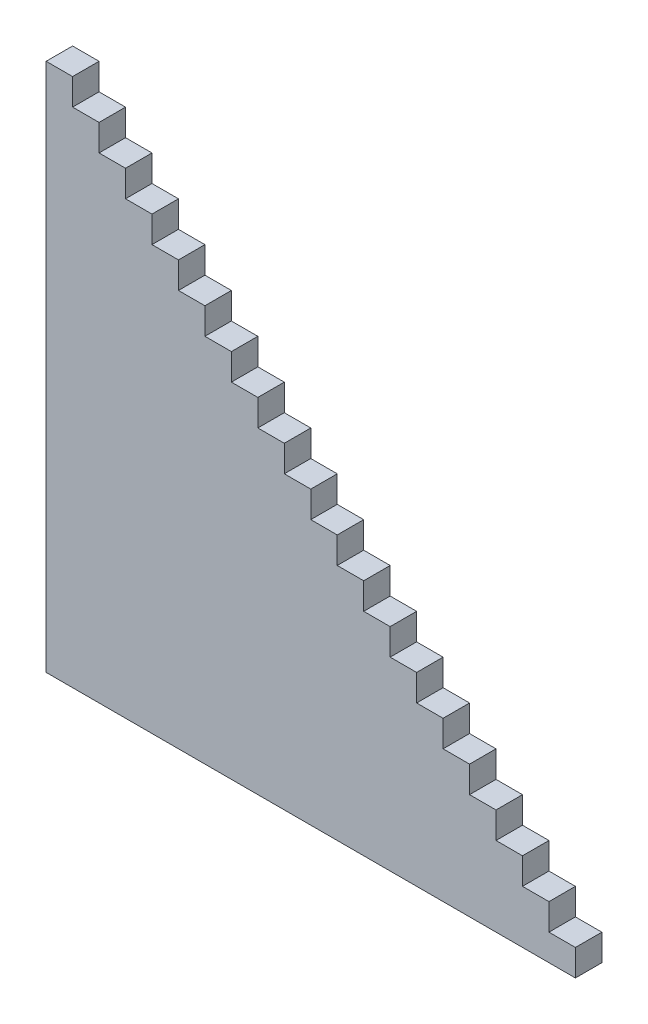
from build123d import *

# Parameters (mm, degrees)
BOSS_EXTRUDE1_DEPTH = 2


with BuildPart() as part:
    # Sketch1 → Boss-Extrude1 (new body)
    with BuildSketch(Plane.XY):
        Polygon((-79.033423275, -42.190980898), (-77.033423275, -42.190980898), (-77.033423275, -44.190980898), (-75.033423275, -44.190980898), (-75.033423275, -46.190980898), (-73.033423275, -46.190980898), (-73.033423275, -48.190980898), (-71.033423275, -48.190980898), (-71.033423275, -50.190980898), (-69.033423275, -50.190980898), (-69.033423275, -52.190980898), (-67.033423275, -52.190980898), (-67.033423275, -54.190980898), (-65.033423275, -54.190980898), (-65.033423275, -56.190980898), (-63.033423275, -56.190980898), (-63.033423275, -58.190980898), (-61.033423275, -58.190980898), (-61.033423275, -60.190980898), (-59.033423275, -60.190980898), (-59.033423275, -62.190980898), (-57.033423275, -62.190980898), (-57.033423275, -64.190980898), (-55.033423275, -64.190980898), (-55.033423275, -66.190980898), (-53.033423275, -66.190980898), (-53.033423275, -68.190980898), (-51.033423275, -68.190980898), (-51.033423275, -70.190980898), (-49.033423275, -70.190980898), (-49.033423275, -72.190980898), (-47.033423275, -72.190980898), (-47.033423275, -74.190980898), (-45.033423275, -74.190980898), (-45.033423275, -76.190980898), (-43.033423275, -76.190980898), (-43.033423275, -78.190980898), (-41.033423275, -78.190980898), (-41.033423275, -80.190980898), (-39.033423275, -80.190980898), (-39.033423275, -82.190980898), (-79.033423275, -82.190980898), (-79.033423275, -80.190980898), (-79.033423275, -78.190980898), (-79.033423275, -76.190980898), (-79.033423275, -74.190980898), (-79.033423275, -72.190980898), (-79.033423275, -70.190980898), (-79.033423275, -68.190980898), (-79.033423275, -66.190980898), (-79.033423275, -64.190980898), (-79.033423275, -62.190980898), (-79.033423275, -60.190980898), (-79.033423275, -58.190980898), (-79.033423275, -56.190980898), (-79.033423275, -54.190980898), (-79.033423275, -52.190980898), (-79.033423275, -50.190980898), (-79.033423275, -48.190980898), (-79.033423275, -46.190980898), (-79.033423275, -44.190980898), align=None)
    extrude(amount=BOSS_EXTRUDE1_DEPTH)


solid = part.part
